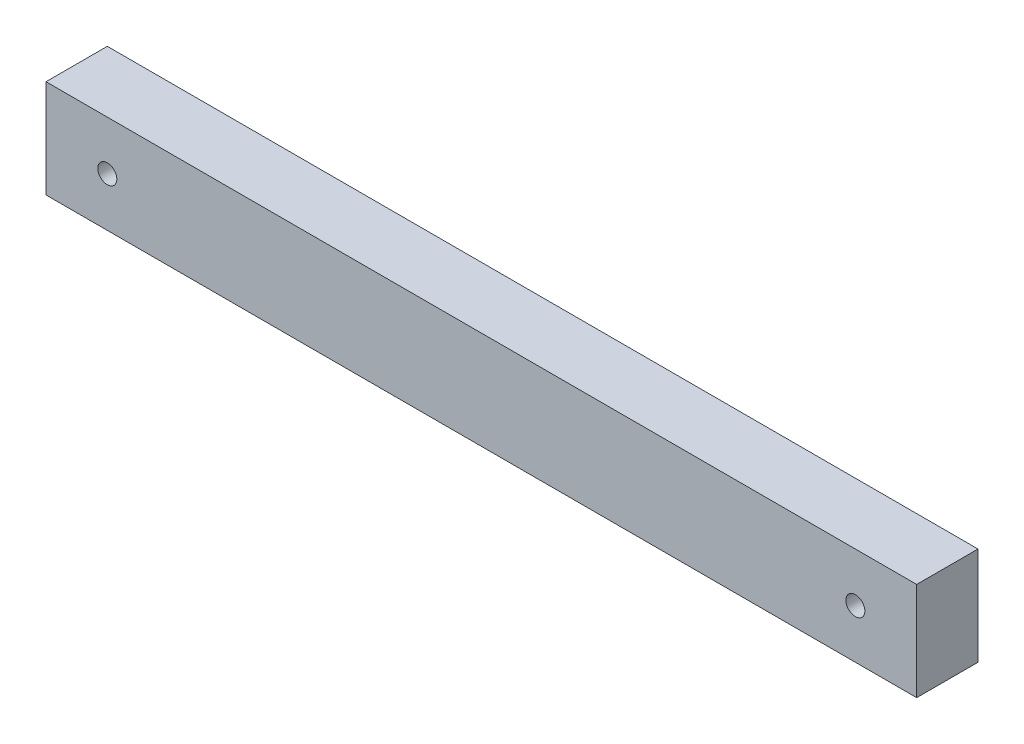
from build123d import *

# Parameters (mm, degrees)
SKETCH1_W           = 142
SKETCH1_H           = 16
SKETCH1_R           = 1.55
BOSS_EXTRUDE1_DEPTH = 10


with BuildPart() as part:
    # Sketch1 → Boss-Extrude1 (new body)
    with BuildSketch(Plane.XY):
        Rectangle(SKETCH1_W, SKETCH1_H)
        with Locations((61, 0)):
            Circle(SKETCH1_R, mode=Mode.SUBTRACT)
        with Locations((-61, 0)):
            Circle(SKETCH1_R, mode=Mode.SUBTRACT)
    extrude(amount=BOSS_EXTRUDE1_DEPTH)


solid = part.part
